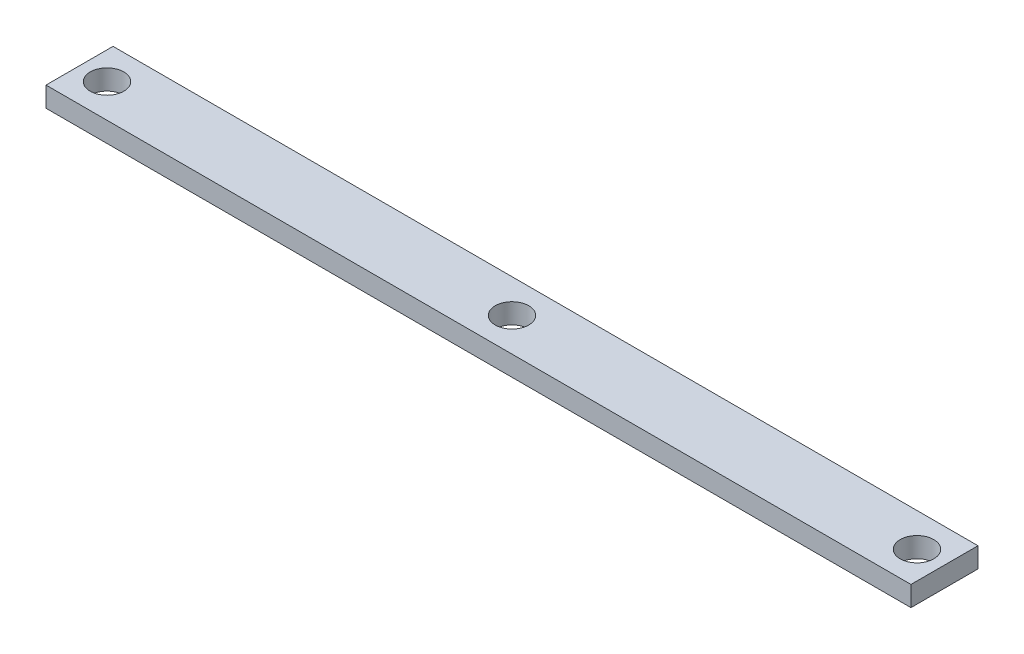
from build123d import *

# Parameters (mm, degrees)
SKETCH1_W              = 129
SKETCH1_H              = 3
BOSS_EXTRUDE1_DEPTH    = 10
SKETCH2_R              = 2.5
CUT_EXTRUDE1_DEPTH     = 4
SKETCH3_W              = 7
SKETCH3_H              = 1
BOSS_EXTRUDE2_DEPTH    = 2
FILLET1_R              = 1
LPATTERN1_COUNT        = 4
LPATTERN1_PITCH        = 12
FILLET1_OF_LPATTERN1_R = 1


with BuildPart() as part:
    # Sketch1 → Boss-Extrude1 (new body)
    with BuildSketch(Plane.XY):
        with Locations((64.5, 1.5)):
            Rectangle(SKETCH1_W, SKETCH1_H)
    extrude(amount=BOSS_EXTRUDE1_DEPTH)

    # Sketch2 → Cut-Extrude1 (cut, through all)
    with BuildSketch(Plane.XZ):
        with Locations(Location((4.1, 5, 0), (0, 0, 270))):  # turned: the seam where the file's is
            Circle(SKETCH2_R)
        with Locations(Location((64.5, 5, 0), (0, 0, 270))):  # turned: the seam where the file's is
            Circle(SKETCH2_R)
        with Locations(Location((124.9, 5, 0), (0, 0, 270))):  # turned: the seam where the file's is
            Circle(SKETCH2_R)
    extrude(amount=-CUT_EXTRUDE1_DEPTH, mode=Mode.SUBTRACT)

    # Sketch3 → Boss-Extrude2 (add)
    with BuildSketch(Plane(origin=(0, 0, 0), x_dir=(1, 0, 0), z_dir=(0, 1, 0))):
        with Locations((13.5, -2.9)):
            Rectangle(SKETCH3_W, SKETCH3_H)
        with Locations((13.5, -7.1)):
            Rectangle(SKETCH3_W, SKETCH3_H)
        with Locations((79.5, -2.9)):
            Rectangle(SKETCH3_W, SKETCH3_H)
        with Locations((79.5, -7.1)):
            Rectangle(SKETCH3_W, SKETCH3_H)
    boss_extrude2 = extrude(amount=-BOSS_EXTRUDE2_DEPTH)

    # Fillet1
    fillet1_edges = [part.edges().sort_by_distance(p)[0] for p in [
        (13.5, 0, 3.4),
        (13.5, 0, 2.4),
        (13.5, 0, 7.6),
        (13.5, 0, 6.6),
        (79.5, 0, 3.4),
        (79.5, 0, 2.4),
        (79.5, 0, 7.6),
        (79.5, 0, 6.6),
    ]]
    fillet(fillet1_edges, radius=FILLET1_R)

    # LPattern1: Boss-Extrude2 ×4
    with Locations(*[(i * LPATTERN1_PITCH, 0, 0) for i in range(1, LPATTERN1_COUNT)]):
        add(boss_extrude2)

    # Fillet1 of LPattern1
    fillet1_of_lpattern1_edges = [part.edges().sort_by_distance(p)[0] for p in [
        (25.5, 0, 3.4),
        (25.5, 0, 2.4),
        (25.5, 0, 7.6),
        (25.5, 0, 6.6),
        (91.5, 0, 3.4),
        (91.5, 0, 2.4),
        (91.5, 0, 7.6),
        (91.5, 0, 6.6),
        (37.5, 0, 3.4),
        (37.5, 0, 2.4),
        (37.5, 0, 7.6),
        (37.5, 0, 6.6),
        (103.5, 0, 3.4),
        (103.5, 0, 2.4),
        (103.5, 0, 7.6),
        (103.5, 0, 6.6),
        (49.5, 0, 3.4),
        (49.5, 0, 2.4),
        (49.5, 0, 7.6),
        (49.5, 0, 6.6),
        (115.5, 0, 3.4),
        (115.5, 0, 2.4),
        (115.5, 0, 7.6),
        (115.5, 0, 6.6),
    ]]
    fillet(fillet1_of_lpattern1_edges, radius=FILLET1_OF_LPATTERN1_R)


solid = part.part
